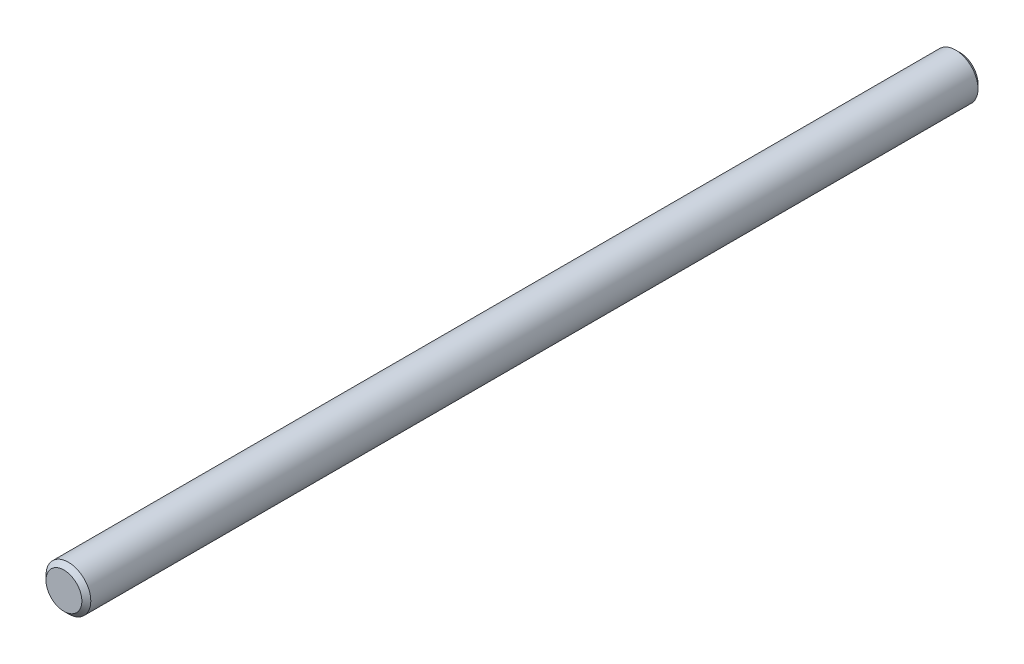
from build123d import *

# Parameters (mm, degrees)
SKETCH1_R      = 5
EXTRUDE1_DEPTH = 100
CHAMFER1_SIZE  = 1


with BuildPart() as part:
    # Sketch1 → Extrude1 (new body, symmetric)
    with BuildSketch(Plane.XY):
        Circle(SKETCH1_R)
    extrude(amount=EXTRUDE1_DEPTH, both=True)

    # Chamfer1
    chamfer1_edges = [part.edges().sort_by_distance(p)[0] for p in [
        (-5, 0, -100),
        (-5, 0, 100),
    ]]
    chamfer(chamfer1_edges, length=CHAMFER1_SIZE)


solid = part.part
